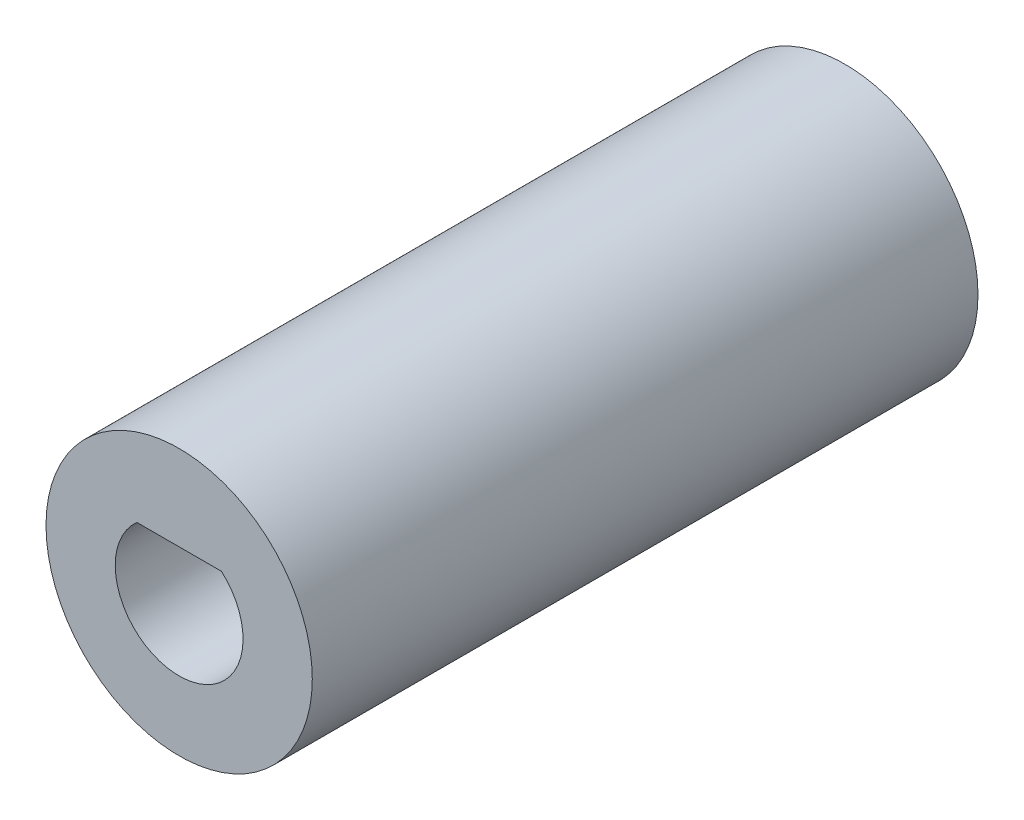
from build123d import *

# Parameters (mm, degrees)
SKETCH1_R           = 6.35
BOSS_EXTRUDE1_DEPTH = 31.75
CUT_EXTRUDE1_DEPTH  = 19.05
SKETCH3_R           = 3.175
CUT_EXTRUDE2_DEPTH  = 12.7


with BuildPart() as part:
    # Sketch1 → Boss-Extrude1 (new body)
    with BuildSketch(Plane.XY):
        Circle(SKETCH1_R)
    extrude(amount=BOSS_EXTRUDE1_DEPTH)

    # Sketch2 → Cut-Extrude1 (cut)
    with BuildSketch(Plane.XY.offset(31.75)):
        with BuildLine():
            Line((2.016062499, 2.286), (-2.016062499, 2.286))
            ThreePointArc((-2.016062499, 2.286), (0, -3.048), (2.016062499, 2.286))
        make_face()
    extrude(amount=-CUT_EXTRUDE1_DEPTH, mode=Mode.SUBTRACT)

    # Sketch3 → Cut-Extrude2 (cut)
    with BuildSketch(Plane(origin=(0, 0, 0), x_dir=(-1, 0, 0), z_dir=(0, 0, -1))):
        Circle(SKETCH3_R)
    extrude(amount=-CUT_EXTRUDE2_DEPTH, mode=Mode.SUBTRACT)


solid = part.part
